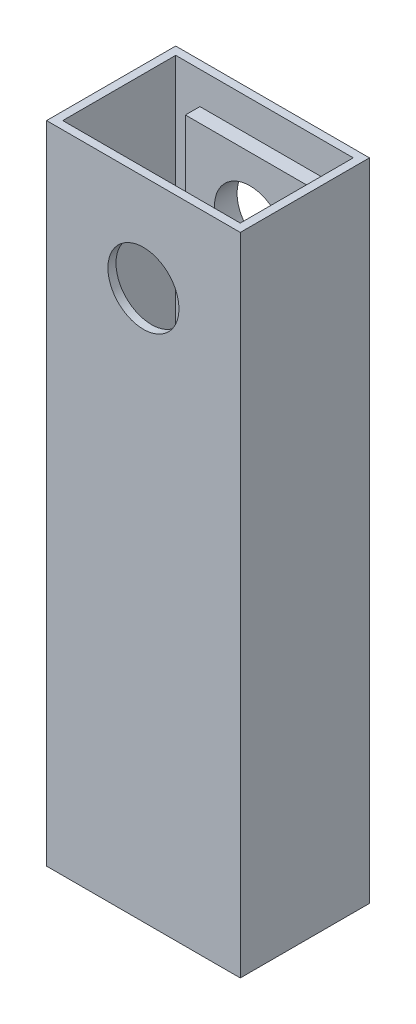
from build123d import *

# Parameters (mm, degrees)
SKETCH1_W           = 60
SKETCH1_H           = 40
SKETCH1_W_2         = 55
SKETCH1_H_2         = 35
BOSS_EXTRUDE1_DEPTH = 200
CUT_EXTRUDE1_DEPTH  = 200
SKETCH3_W           = 40
SKETCH3_H           = 40
SKETCH3_R           = 11
BOSS_EXTRUDE2_DEPTH = 4.5


with BuildPart() as part:
    # Sketch1 → Boss-Extrude1 (new body)
    with BuildSketch(Plane(origin=(0, 0, 0), x_dir=(1, 0, 0), z_dir=(0, 1, 0))):
        with Locations((-30, -20)):
            Rectangle(SKETCH1_W, SKETCH1_H)
        with Locations((-30, -20)):
            Rectangle(SKETCH1_W_2, SKETCH1_H_2, mode=Mode.SUBTRACT)
    extrude(amount=BOSS_EXTRUDE1_DEPTH)

    # Sketch2 → Cut-Extrude1 (cut)
    with BuildSketch(Plane(origin=(0, 0, 0), x_dir=(-1, 0, 0), z_dir=(0, 0, -1))):
        with BuildLine():
            ThreePointArc((41, 170), (34.209518, 180.162675), (22.221825, 177.778175))
            Line((22.221825, 177.778175), (37.778175, 162.221825))
            ThreePointArc((37.778175, 162.221825), (40.162675, 165.790482), (41, 170))
        make_face()
        with BuildLine():
            Line((37.778175, 162.221825), (22.221825, 177.778175))
            ThreePointArc((22.221825, 177.778175), (22.221825, 162.221825), (37.778175, 162.221825))
        make_face()
    extrude(amount=-CUT_EXTRUDE1_DEPTH, mode=Mode.SUBTRACT)

    # Sketch3 → Boss-Extrude2 (add)
    with BuildSketch(Plane.XY.offset(2.5)):
        with Locations((-30, 170)):
            Rectangle(SKETCH3_W, SKETCH3_H)
        with Locations((-30, 170)):
            Circle(SKETCH3_R, mode=Mode.SUBTRACT)
    extrude(amount=BOSS_EXTRUDE2_DEPTH)


solid = part.part
